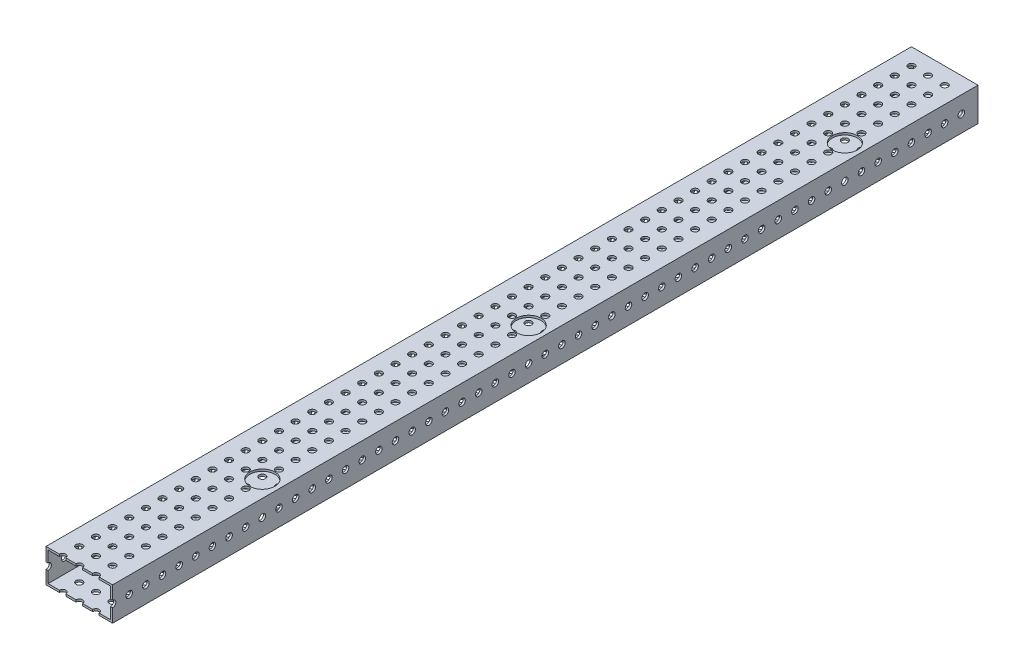
from build123d import *

# Parameters (mm, degrees)
SKETCH1_W           = 50.8
SKETCH1_H           = 25.4
SKETCH1_W_2         = 47.625
SKETCH1_H_2         = 22.225
BOSS_EXTRUDE1_DEPTH = 660.4
SKETCH2_R           = 2.4892
CUT_EXTRUDE1_DEPTH  = 26.4
SKETCH3_R           = 2.4892
CUT_EXTRUDE2_DEPTH  = 51.8
SKETCH4_R           = 9.525
CUT_EXTRUDE3_DEPTH  = 26.4


with BuildPart() as part:
    # Sketch1 → Boss-Extrude1 (new body)
    with BuildSketch(Plane.XY):
        with Locations((25.4, 12.7)):
            Rectangle(SKETCH1_W, SKETCH1_H)
        with Locations((25.4, 12.7)):
            Rectangle(SKETCH1_W_2, SKETCH1_H_2, mode=Mode.SUBTRACT)
    extrude(amount=BOSS_EXTRUDE1_DEPTH)

    # Sketch2 → Cut-Extrude1 (cut, through all)
    with BuildSketch(Plane(origin=(0, 25.4, 0), x_dir=(1, 0, 0), z_dir=(0, 1, 0))):
        with Locations((12.7, -12.7)):
            Circle(SKETCH2_R)
        with Locations((25.4, -12.7)):
            Circle(SKETCH2_R)
        with Locations((38.1, -12.7)):
            Circle(SKETCH2_R)
        with Locations((25.4, -25.4)):
            Circle(SKETCH2_R)
        with Locations((38.1, -25.4)):
            Circle(SKETCH2_R)
        with Locations((25.4, -38.1)):
            Circle(SKETCH2_R)
        with Locations((38.1, -38.1)):
            Circle(SKETCH2_R)
        with Locations((25.4, -50.8)):
            Circle(SKETCH2_R)
        with Locations((38.1, -50.8)):
            Circle(SKETCH2_R)
        with Locations((25.4, -63.5)):
            Circle(SKETCH2_R)
        with Locations((38.1, -63.5)):
            Circle(SKETCH2_R)
        with Locations((25.4, -76.2)):
            Circle(SKETCH2_R)
        with Locations((38.1, -76.2)):
            Circle(SKETCH2_R)
        with Locations((25.4, -88.9)):
            Circle(SKETCH2_R)
        with Locations((38.1, -88.9)):
            Circle(SKETCH2_R)
        with Locations((25.4, -101.6)):
            Circle(SKETCH2_R)
        with Locations((38.1, -101.6)):
            Circle(SKETCH2_R)
        with Locations((25.4, -114.3)):
            Circle(SKETCH2_R)
        with Locations((38.1, -114.3)):
            Circle(SKETCH2_R)
        with Locations((25.4, -127)):
            Circle(SKETCH2_R)
        with Locations((38.1, -127)):
            Circle(SKETCH2_R)
        with Locations((25.4, -139.7)):
            Circle(SKETCH2_R)
        with Locations((38.1, -139.7)):
            Circle(SKETCH2_R)
        with Locations((25.4, -152.4)):
            Circle(SKETCH2_R)
        with Locations((38.1, -152.4)):
            Circle(SKETCH2_R)
        with Locations((25.4, -165.1)):
            Circle(SKETCH2_R)
        with Locations((38.1, -165.1)):
            Circle(SKETCH2_R)
        with Locations((25.4, -177.8)):
            Circle(SKETCH2_R)
        with Locations((38.1, -177.8)):
            Circle(SKETCH2_R)
        with Locations((25.4, -190.5)):
            Circle(SKETCH2_R)
        with Locations((38.1, -190.5)):
            Circle(SKETCH2_R)
        with Locations((25.4, -203.2)):
            Circle(SKETCH2_R)
        with Locations((38.1, -203.2)):
            Circle(SKETCH2_R)
        with Locations((25.4, -215.9)):
            Circle(SKETCH2_R)
        with Locations((38.1, -215.9)):
            Circle(SKETCH2_R)
        with Locations((25.4, -228.6)):
            Circle(SKETCH2_R)
        with Locations((38.1, -228.6)):
            Circle(SKETCH2_R)
        with Locations((25.4, -241.3)):
            Circle(SKETCH2_R)
        with Locations((38.1, -241.3)):
            Circle(SKETCH2_R)
        with Locations((25.4, -254)):
            Circle(SKETCH2_R)
        with Locations((38.1, -254)):
            Circle(SKETCH2_R)
        with Locations((25.4, -266.7)):
            Circle(SKETCH2_R)
        with Locations((38.1, -266.7)):
            Circle(SKETCH2_R)
        with Locations((25.4, -279.4)):
            Circle(SKETCH2_R)
        with Locations((38.1, -279.4)):
            Circle(SKETCH2_R)
        with Locations((25.4, -292.1)):
            Circle(SKETCH2_R)
        with Locations((38.1, -292.1)):
            Circle(SKETCH2_R)
        with Locations((25.4, -304.8)):
            Circle(SKETCH2_R)
        with Locations((38.1, -304.8)):
            Circle(SKETCH2_R)
        with Locations((25.4, -317.5)):
            Circle(SKETCH2_R)
        with Locations((38.1, -317.5)):
            Circle(SKETCH2_R)
        with Locations((25.4, -330.2)):
            Circle(SKETCH2_R)
        with Locations((38.1, -330.2)):
            Circle(SKETCH2_R)
        with Locations((25.4, -342.9)):
            Circle(SKETCH2_R)
        with Locations((38.1, -342.9)):
            Circle(SKETCH2_R)
        with Locations((25.4, -355.6)):
            Circle(SKETCH2_R)
        with Locations((38.1, -355.6)):
            Circle(SKETCH2_R)
        with Locations((25.4, -368.3)):
            Circle(SKETCH2_R)
        with Locations((38.1, -368.3)):
            Circle(SKETCH2_R)
        with Locations((25.4, -381)):
            Circle(SKETCH2_R)
        with Locations((38.1, -381)):
            Circle(SKETCH2_R)
        with Locations((25.4, -393.7)):
            Circle(SKETCH2_R)
        with Locations((38.1, -393.7)):
            Circle(SKETCH2_R)
        with Locations((25.4, -406.4)):
            Circle(SKETCH2_R)
        with Locations((38.1, -406.4)):
            Circle(SKETCH2_R)
        with Locations((25.4, -419.1)):
            Circle(SKETCH2_R)
        with Locations((38.1, -419.1)):
            Circle(SKETCH2_R)
        with Locations((25.4, -431.8)):
            Circle(SKETCH2_R)
        with Locations((38.1, -431.8)):
            Circle(SKETCH2_R)
        with Locations((25.4, -444.5)):
            Circle(SKETCH2_R)
        with Locations((38.1, -444.5)):
            Circle(SKETCH2_R)
        with Locations((25.4, -457.2)):
            Circle(SKETCH2_R)
        with Locations((38.1, -457.2)):
            Circle(SKETCH2_R)
        with Locations((25.4, -469.9)):
            Circle(SKETCH2_R)
        with Locations((38.1, -469.9)):
            Circle(SKETCH2_R)
        with Locations((25.4, -482.6)):
            Circle(SKETCH2_R)
        with Locations((38.1, -482.6)):
            Circle(SKETCH2_R)
        with Locations((25.4, -495.3)):
            Circle(SKETCH2_R)
        with Locations((38.1, -495.3)):
            Circle(SKETCH2_R)
        with Locations((25.4, -508)):
            Circle(SKETCH2_R)
        with Locations((38.1, -508)):
            Circle(SKETCH2_R)
        with Locations((25.4, -520.7)):
            Circle(SKETCH2_R)
        with Locations((38.1, -520.7)):
            Circle(SKETCH2_R)
        with Locations((25.4, -533.4)):
            Circle(SKETCH2_R)
        with Locations((38.1, -533.4)):
            Circle(SKETCH2_R)
        with Locations((25.4, -546.1)):
            Circle(SKETCH2_R)
        with Locations((38.1, -546.1)):
            Circle(SKETCH2_R)
        with Locations((25.4, -558.8)):
            Circle(SKETCH2_R)
        with Locations((38.1, -558.8)):
            Circle(SKETCH2_R)
        with Locations((25.4, -571.5)):
            Circle(SKETCH2_R)
        with Locations((38.1, -571.5)):
            Circle(SKETCH2_R)
        with Locations((25.4, -584.2)):
            Circle(SKETCH2_R)
        with Locations((38.1, -584.2)):
            Circle(SKETCH2_R)
        with Locations((25.4, -596.9)):
            Circle(SKETCH2_R)
        with Locations((38.1, -596.9)):
            Circle(SKETCH2_R)
        with Locations((25.4, -609.6)):
            Circle(SKETCH2_R)
        with Locations((38.1, -609.6)):
            Circle(SKETCH2_R)
        with Locations((25.4, -622.3)):
            Circle(SKETCH2_R)
        with Locations((38.1, -622.3)):
            Circle(SKETCH2_R)
        with Locations((25.4, -635)):
            Circle(SKETCH2_R)
        with Locations((38.1, -635)):
            Circle(SKETCH2_R)
        with Locations((25.4, -647.7)):
            Circle(SKETCH2_R)
        with Locations((38.1, -647.7)):
            Circle(SKETCH2_R)
        with Locations((25.4, -660.4)):
            Circle(SKETCH2_R)
        with Locations((38.1, -660.4)):
            Circle(SKETCH2_R)
        with Locations((12.7, -25.4)):
            Circle(SKETCH2_R)
        with Locations((12.7, -38.1)):
            Circle(SKETCH2_R)
        with Locations((12.7, -50.8)):
            Circle(SKETCH2_R)
        with Locations((12.7, -63.5)):
            Circle(SKETCH2_R)
        with Locations((12.7, -76.2)):
            Circle(SKETCH2_R)
        with Locations((12.7, -88.9)):
            Circle(SKETCH2_R)
        with Locations((12.7, -101.6)):
            Circle(SKETCH2_R)
        with Locations((12.7, -114.3)):
            Circle(SKETCH2_R)
        with Locations((12.7, -127)):
            Circle(SKETCH2_R)
        with Locations((12.7, -139.7)):
            Circle(SKETCH2_R)
        with Locations((12.7, -152.4)):
            Circle(SKETCH2_R)
        with Locations((12.7, -165.1)):
            Circle(SKETCH2_R)
        with Locations((12.7, -177.8)):
            Circle(SKETCH2_R)
        with Locations((12.7, -190.5)):
            Circle(SKETCH2_R)
        with Locations((12.7, -203.2)):
            Circle(SKETCH2_R)
        with Locations((12.7, -215.9)):
            Circle(SKETCH2_R)
        with Locations((12.7, -228.6)):
            Circle(SKETCH2_R)
        with Locations((12.7, -241.3)):
            Circle(SKETCH2_R)
        with Locations((12.7, -254)):
            Circle(SKETCH2_R)
        with Locations((12.7, -266.7)):
            Circle(SKETCH2_R)
        with Locations((12.7, -279.4)):
            Circle(SKETCH2_R)
        with Locations((12.7, -292.1)):
            Circle(SKETCH2_R)
        with Locations((12.7, -304.8)):
            Circle(SKETCH2_R)
        with Locations((12.7, -317.5)):
            Circle(SKETCH2_R)
        with Locations((12.7, -330.2)):
            Circle(SKETCH2_R)
        with Locations((12.7, -342.9)):
            Circle(SKETCH2_R)
        with Locations((12.7, -355.6)):
            Circle(SKETCH2_R)
        with Locations((12.7, -368.3)):
            Circle(SKETCH2_R)
        with Locations((12.7, -381)):
            Circle(SKETCH2_R)
        with Locations((12.7, -393.7)):
            Circle(SKETCH2_R)
        with Locations((12.7, -406.4)):
            Circle(SKETCH2_R)
        with Locations((12.7, -419.1)):
            Circle(SKETCH2_R)
        with Locations((12.7, -431.8)):
            Circle(SKETCH2_R)
        with Locations((12.7, -444.5)):
            Circle(SKETCH2_R)
        with Locations((12.7, -457.2)):
            Circle(SKETCH2_R)
        with Locations((12.7, -469.9)):
            Circle(SKETCH2_R)
        with Locations((12.7, -482.6)):
            Circle(SKETCH2_R)
        with Locations((12.7, -495.3)):
            Circle(SKETCH2_R)
        with Locations((12.7, -508)):
            Circle(SKETCH2_R)
        with Locations((12.7, -520.7)):
            Circle(SKETCH2_R)
        with Locations((12.7, -533.4)):
            Circle(SKETCH2_R)
        with Locations((12.7, -546.1)):
            Circle(SKETCH2_R)
        with Locations((12.7, -558.8)):
            Circle(SKETCH2_R)
        with Locations((12.7, -571.5)):
            Circle(SKETCH2_R)
        with Locations((12.7, -584.2)):
            Circle(SKETCH2_R)
        with Locations((12.7, -596.9)):
            Circle(SKETCH2_R)
        with Locations((12.7, -609.6)):
            Circle(SKETCH2_R)
        with Locations((12.7, -622.3)):
            Circle(SKETCH2_R)
        with Locations((12.7, -635)):
            Circle(SKETCH2_R)
        with Locations((12.7, -647.7)):
            Circle(SKETCH2_R)
        with Locations((12.7, -660.4)):
            Circle(SKETCH2_R)
    extrude(amount=-CUT_EXTRUDE1_DEPTH, mode=Mode.SUBTRACT)

    # Sketch3 → Cut-Extrude2 (cut, through all)
    with BuildSketch(Plane.ZY):
        with Locations((12.7, 12.7)):
            Circle(SKETCH3_R)
        with Locations((25.4, 12.7)):
            Circle(SKETCH3_R)
        with Locations((38.1, 12.7)):
            Circle(SKETCH3_R)
        with Locations((50.8, 12.7)):
            Circle(SKETCH3_R)
        with Locations((63.5, 12.7)):
            Circle(SKETCH3_R)
        with Locations((76.2, 12.7)):
            Circle(SKETCH3_R)
        with Locations((88.9, 12.7)):
            Circle(SKETCH3_R)
        with Locations((101.6, 12.7)):
            Circle(SKETCH3_R)
        with Locations((114.3, 12.7)):
            Circle(SKETCH3_R)
        with Locations((127, 12.7)):
            Circle(SKETCH3_R)
        with Locations((139.7, 12.7)):
            Circle(SKETCH3_R)
        with Locations((152.4, 12.7)):
            Circle(SKETCH3_R)
        with Locations((165.1, 12.7)):
            Circle(SKETCH3_R)
        with Locations((177.8, 12.7)):
            Circle(SKETCH3_R)
        with Locations((190.5, 12.7)):
            Circle(SKETCH3_R)
        with Locations((203.2, 12.7)):
            Circle(SKETCH3_R)
        with Locations((215.9, 12.7)):
            Circle(SKETCH3_R)
        with Locations((228.6, 12.7)):
            Circle(SKETCH3_R)
        with Locations((241.3, 12.7)):
            Circle(SKETCH3_R)
        with Locations((254, 12.7)):
            Circle(SKETCH3_R)
        with Locations((266.7, 12.7)):
            Circle(SKETCH3_R)
        with Locations((279.4, 12.7)):
            Circle(SKETCH3_R)
        with Locations((292.1, 12.7)):
            Circle(SKETCH3_R)
        with Locations((304.8, 12.7)):
            Circle(SKETCH3_R)
        with Locations((317.5, 12.7)):
            Circle(SKETCH3_R)
        with Locations((330.2, 12.7)):
            Circle(SKETCH3_R)
        with Locations((342.9, 12.7)):
            Circle(SKETCH3_R)
        with Locations((355.6, 12.7)):
            Circle(SKETCH3_R)
        with Locations((368.3, 12.7)):
            Circle(SKETCH3_R)
        with Locations((381, 12.7)):
            Circle(SKETCH3_R)
        with Locations((393.7, 12.7)):
            Circle(SKETCH3_R)
        with Locations((406.4, 12.7)):
            Circle(SKETCH3_R)
        with Locations((419.1, 12.7)):
            Circle(SKETCH3_R)
        with Locations((431.8, 12.7)):
            Circle(SKETCH3_R)
        with Locations((444.5, 12.7)):
            Circle(SKETCH3_R)
        with Locations((457.2, 12.7)):
            Circle(SKETCH3_R)
        with Locations((469.9, 12.7)):
            Circle(SKETCH3_R)
        with Locations((482.6, 12.7)):
            Circle(SKETCH3_R)
        with Locations((495.3, 12.7)):
            Circle(SKETCH3_R)
        with Locations((508, 12.7)):
            Circle(SKETCH3_R)
        with Locations((520.7, 12.7)):
            Circle(SKETCH3_R)
        with Locations((533.4, 12.7)):
            Circle(SKETCH3_R)
        with Locations((546.1, 12.7)):
            Circle(SKETCH3_R)
        with Locations((558.8, 12.7)):
            Circle(SKETCH3_R)
        with Locations((571.5, 12.7)):
            Circle(SKETCH3_R)
        with Locations((584.2, 12.7)):
            Circle(SKETCH3_R)
        with Locations((596.9, 12.7)):
            Circle(SKETCH3_R)
        with Locations((609.6, 12.7)):
            Circle(SKETCH3_R)
        with Locations((622.3, 12.7)):
            Circle(SKETCH3_R)
        with Locations((635, 12.7)):
            Circle(SKETCH3_R)
        with Locations((647.7, 12.7)):
            Circle(SKETCH3_R)
        with Locations((660.4, 12.7)):
            Circle(SKETCH3_R)
    extrude(amount=-CUT_EXTRUDE2_DEPTH, mode=Mode.SUBTRACT)

    # Sketch4 → Cut-Extrude3 (cut, through all)
    with BuildSketch(Plane.XZ):
        with Locations((38.1, 330.2)):
            Circle(SKETCH4_R)
        with Locations((38.1, 88.9)):
            Circle(SKETCH4_R)
        with Locations((38.1, 533.4)):
            Circle(SKETCH4_R)
    extrude(amount=-CUT_EXTRUDE3_DEPTH, mode=Mode.SUBTRACT)


solid = part.part
